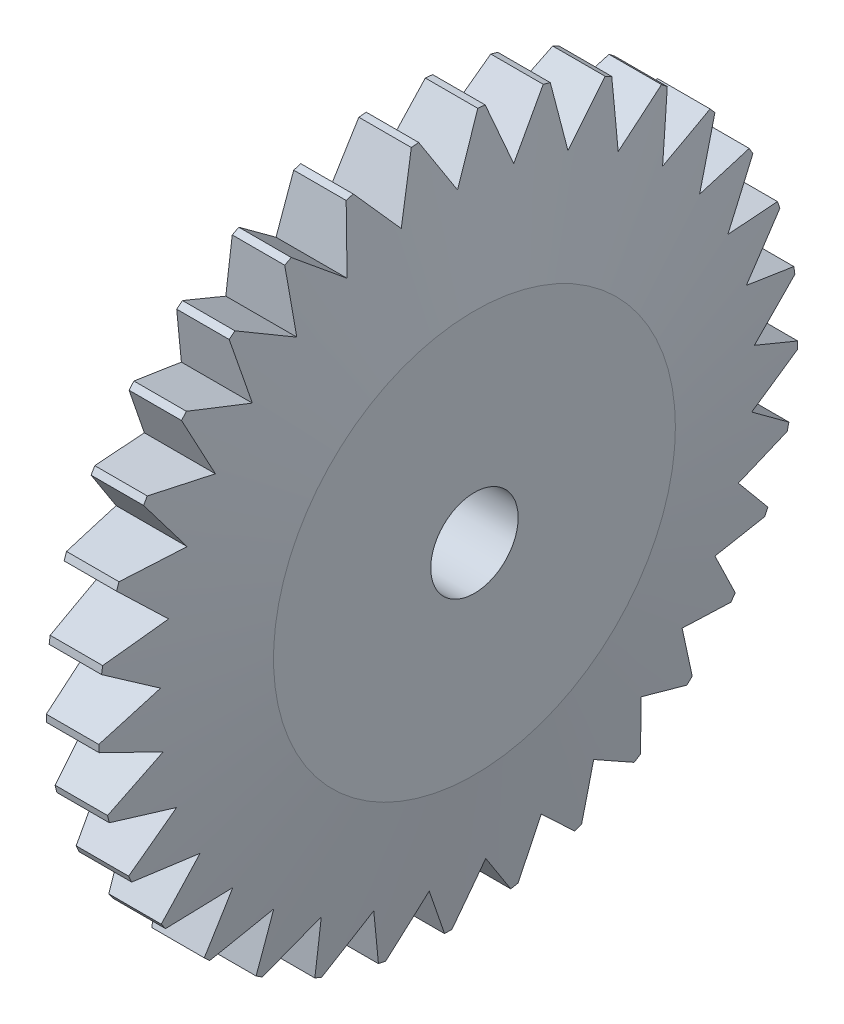
from build123d import *

# Parameters (mm, degrees)
SKETCH1_R           = 40
SKETCH1_R_2         = 5
BOSS_EXTRUDE1_DEPTH = 6
CHAMFER2_SIZE       = 3
CHAMFER2_SIZE2      = 17.013845459
CHAMFER3_SIZE       = 3
CHAMFER3_SIZE2      = 17.013845459
CUT_EXTRUDE2_DEPTH  = 12
CIRPATTERN2_COUNT   = 33


with BuildPart() as part:
    # Sketch1 → Boss-Extrude1 (new body, symmetric)
    with BuildSketch(Plane(origin=(0, 0, 0), x_dir=(0, 0, -1), z_dir=(1, 0, 0))):
        Circle(SKETCH1_R)
        Circle(SKETCH1_R_2, mode=Mode.SUBTRACT)
    extrude(amount=BOSS_EXTRUDE1_DEPTH, both=True)

    # Chamfer2
    chamfer2_edges = [part.edges().sort_by_distance(p)[0] for p in [
        (6, 0, 40),
    ]]
    chamfer2_side = [part.faces().sort_by_distance(p)[0] for p in [
        (0, 0, 40),
    ]]
    chamfer(chamfer2_edges, length=CHAMFER2_SIZE, length2=CHAMFER2_SIZE2, reference=chamfer2_side[0])

    # Chamfer3
    chamfer3_edges = [part.edges().sort_by_distance(p)[0] for p in [
        (-6, 0, 40),
    ]]
    chamfer3_side = [part.faces().sort_by_distance(p)[0] for p in [
        (-1.5, 0, 40),
    ]]
    chamfer(chamfer3_edges, length=CHAMFER3_SIZE, length2=CHAMFER3_SIZE2, reference=chamfer3_side[0])

    # Sketch2 → Cut-Extrude2 (cut)
    with BuildSketch(Plane(origin=(6, 0, 0), x_dir=(0, 0, -1), z_dir=(1, 0, 0))):
        with BuildLine():
            Line((0, 34), (3.381435126, 39.856817441))
            ThreePointArc((3.381435126, 39.856817441), (0, 40.762870252), (-3.381435126, 39.856817441))
            Line((-3.381435126, 39.856817441), (0, 34))
        make_face()
    cut_extrude2 = extrude(amount=-CUT_EXTRUDE2_DEPTH, mode=Mode.SUBTRACT)

    # CirPattern2: Cut-Extrude2 ×33 about axis
    cirpattern2_axis = Axis((0, 0, 0), (1, 0, 0))
    for i in range(1, CIRPATTERN2_COUNT):
        add(cut_extrude2.rotate(cirpattern2_axis, i * 360 / CIRPATTERN2_COUNT), mode=Mode.SUBTRACT)


solid = part.part
